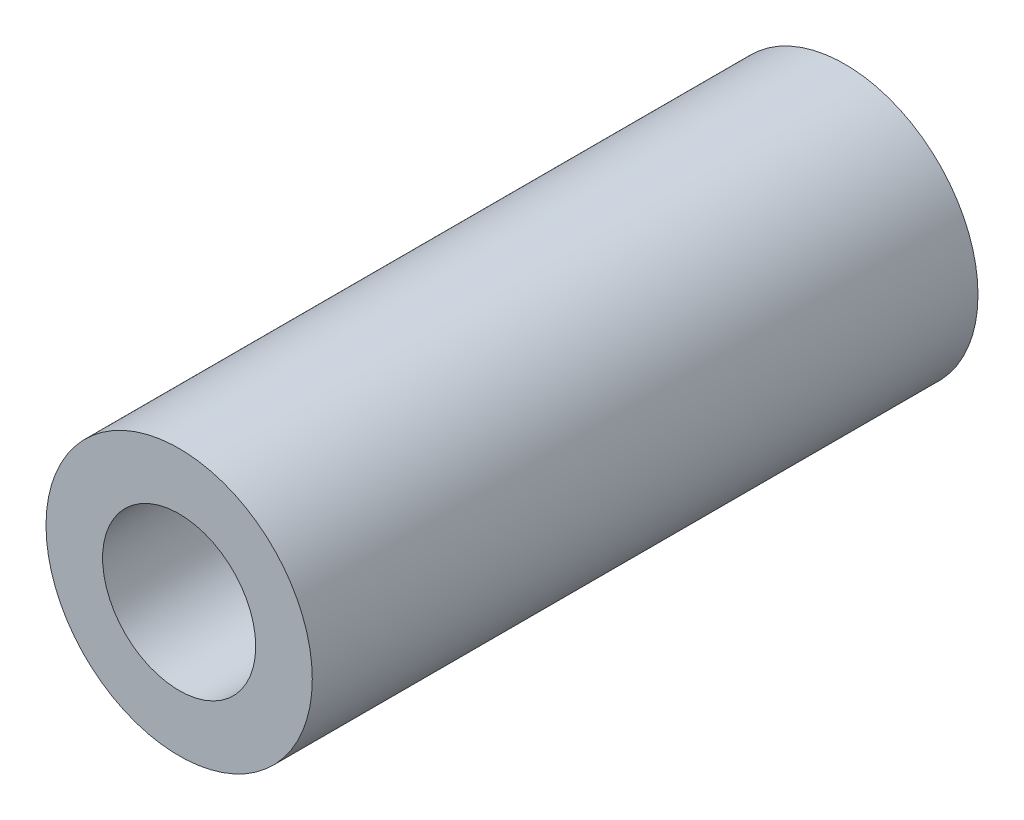
from build123d import *

# Parameters (mm, degrees)
SKETCH9_R           = 2
BOSS_EXTRUDE3_DEPTH = 10
SKETCH12_R          = 1.15
CUT_EXTRUDE2_DEPTH  = 11


with BuildPart() as part:
    # Sketch9 → Boss-Extrude3 (new body)
    with BuildSketch(Plane.XY):
        with Locations((-11.902732449, 30.059442964)):
            Circle(SKETCH9_R)
    extrude(amount=BOSS_EXTRUDE3_DEPTH)

    # Sketch12 → Cut-Extrude2 (cut, through all)
    with BuildSketch(Plane.XY.offset(10)):
        with Locations((-11.902732449, 30.059442964)):
            Circle(SKETCH12_R)
    extrude(amount=-CUT_EXTRUDE2_DEPTH, mode=Mode.SUBTRACT)


solid = part.part
